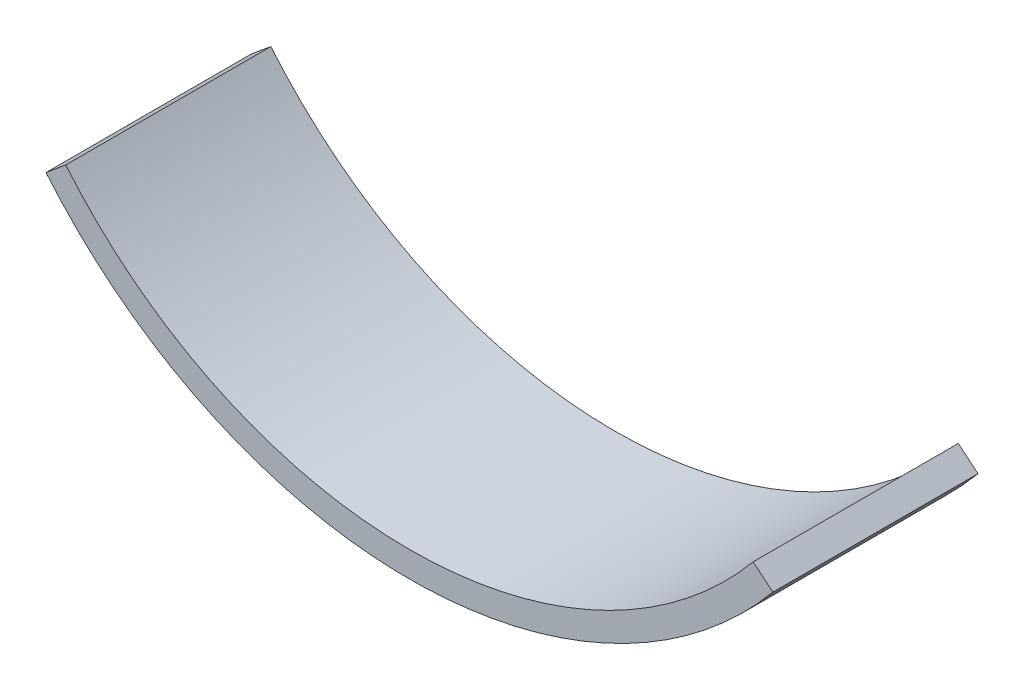
from build123d import *

# Parameters (mm, degrees)
BOSS_EXTRUDE1_DEPTH = 25.4


with BuildPart() as part:
    # Sketch1 → Boss-Extrude1 (new body)
    with BuildSketch(Plane.XY):
        with BuildLine():
            Line((0, 0), (2.440430438, 2.030990959))
            ThreePointArc((2.440430438, 2.030990959), (45, -17.919806075), (87.559569562, 2.030990959))
            Line((87.559569562, 2.030990959), (90, 0))
            ThreePointArc((90, 0), (45, -21.094806075), (0, 0))
        make_face()
    extrude(amount=BOSS_EXTRUDE1_DEPTH)


solid = part.part
